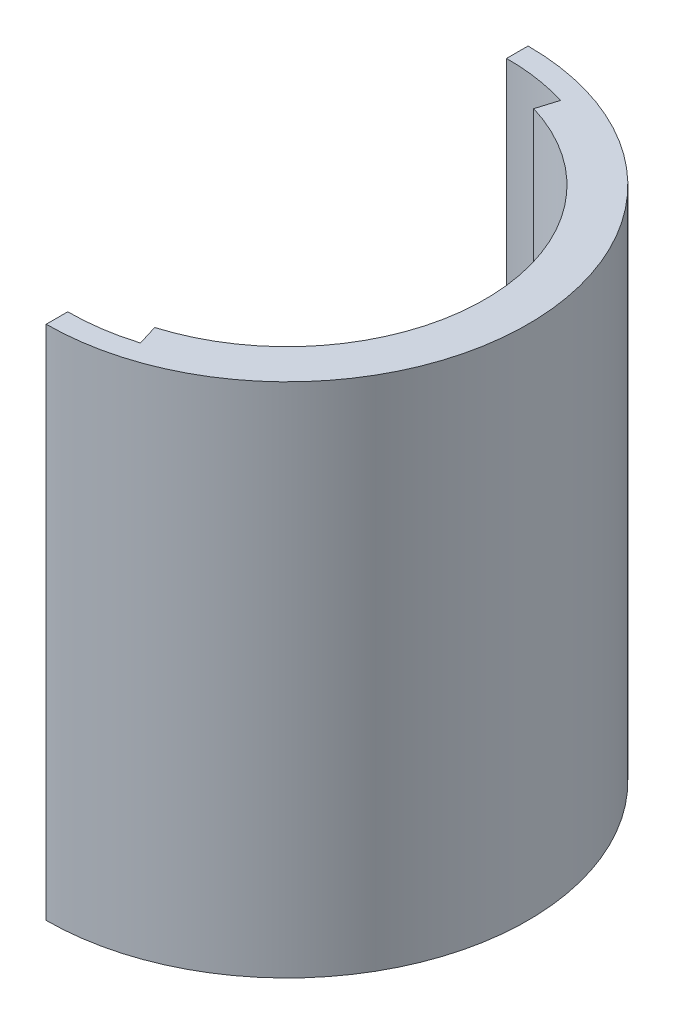
from build123d import *

# Parameters (mm, degrees)
SKETCH2_R           = 28
BOSS_EXTRUDE1_DEPTH = 60
SKETCH3_R           = 23
CUT_EXTRUDE2_DEPTH  = 72.888803022
CUT_EXTRUDE3_DEPTH  = 72.888803022


with BuildPart() as part:
    # Sketch2 → Boss-Extrude1 (new body)
    with BuildSketch(Plane(origin=(0, 0, 0), x_dir=(1, 0, 0), z_dir=(0, 1, 0))):
        with Locations(Location((0, 0, 0), (0, 0, 270))):
            Circle(SKETCH2_R)
    extrude(amount=BOSS_EXTRUDE1_DEPTH)

    # Sketch3 → Cut-Extrude2 (cut, through all)
    with BuildSketch(Plane.XZ):
        with Locations(Location((0, 0, 0), (0, 0, 270))):
            Circle(SKETCH3_R)
    extrude(amount=-CUT_EXTRUDE2_DEPTH, mode=Mode.SUBTRACT)

    # Sketch5 → Cut-Extrude3 (cut, through all)
    with BuildSketch(Plane.XZ):
        with BuildLine():
            Line((0, 28), (0, 25.5))
            ThreePointArc((0, 25.5), (3.722882581, 25.226774373), (7.365985795, 24.412952572))
            Line((7.365985795, 24.412952572), (6.634014205, 22.022485226))
            ThreePointArc((6.634014205, 22.022485226), (-23.141150891, 0), (6.634014205, -22.022485226))
            Line((6.634014205, -22.022485226), (7.365978971, -24.412930285))
            ThreePointArc((7.365978971, -24.412930285), (3.723999827, -25.234351011), (0, -25.5))
            Line((0, -25.5), (0, -28))
            ThreePointArc((0, -28), (-28, 0), (0, 28))
        make_face()
    extrude(amount=-CUT_EXTRUDE3_DEPTH, mode=Mode.SUBTRACT)


with BuildPart() as body_2:
    # of the pieces the cut leaves, the one that is kept (cut_extrude3_keep)
    add(part.part.solids().sort_by_distance((0, 0, 28))[0])


solid = body_2.part
